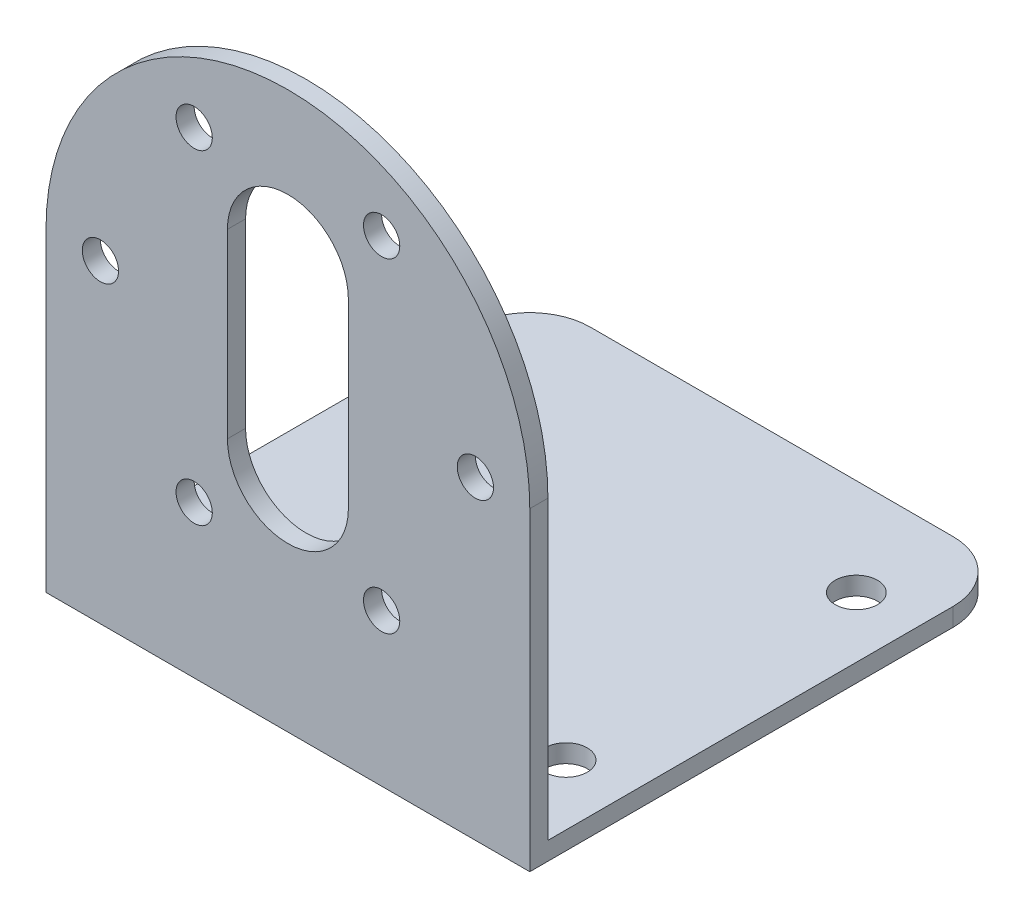
from build123d import *

# Parameters (mm, degrees)
SKETCH_1_R          = 1.5
EXTRUDE_1_DEPTH     = 1.5
SKETCH_2_W          = 40
SKETCH_2_H          = 1.5
EXTRUDE_2_DEPTH     = 38.5
SKETCH_3_R          = 1.75
CUT_EXTRUDE_1_DEPTH = 47
FILLET_1_R          = 5


with BuildPart() as part:
    # 草图1 → 凸台-拉伸1 (new body)
    with BuildSketch(Plane.XY):
        with BuildLine():
            Line((-20, 0), (-20, -26))
            Line((-20, -26), (20, -26))
            Line((20, -26), (20, 0))
            ThreePointArc((20, 0), (0, 20), (-20, 0))
        make_face()
        with Locations((7.75, 13.423393759)):
            Circle(SKETCH_1_R, mode=Mode.SUBTRACT)
        with Locations((-7.75, 13.423393759)):
            Circle(SKETCH_1_R, mode=Mode.SUBTRACT)
        with Locations((-15.5, 0)):
            Circle(SKETCH_1_R, mode=Mode.SUBTRACT)
        with Locations((-7.75, -13.423393759)):
            Circle(SKETCH_1_R, mode=Mode.SUBTRACT)
        with Locations((7.75, -13.423393759)):
            Circle(SKETCH_1_R, mode=Mode.SUBTRACT)
        with Locations((15.5, 0)):
            Circle(SKETCH_1_R, mode=Mode.SUBTRACT)
        with BuildLine():
            Line((5, -7.5), (5, 7.5))
            ThreePointArc((5, 7.5), (0, 12.5), (-5, 7.5))
            Line((-5, 7.5), (-5, -7.5))
            ThreePointArc((-5, -7.5), (0, -12.5), (5, -7.5))
        make_face(mode=Mode.SUBTRACT)
    extrude(amount=EXTRUDE_1_DEPTH)

    # 草图2 → 凸台-拉伸2 (add)
    with BuildSketch(Plane(origin=(0, 0, 0), x_dir=(-1, 0, 0), z_dir=(0, 0, -1))):
        with Locations((0, -25.25)):
            Rectangle(SKETCH_2_W, SKETCH_2_H)
    extrude(amount=EXTRUDE_2_DEPTH)

    # 草图3 → 切除-拉伸1 (cut, through all)
    with BuildSketch(Plane.XZ.offset(26)):
        with Locations((-15, -6.5)):
            Circle(SKETCH_3_R)
        with Locations((15, -6.5)):
            Circle(SKETCH_3_R)
        with Locations((-15, -30.5)):
            Circle(SKETCH_3_R)
        with Locations((15, -30.5)):
            Circle(SKETCH_3_R)
    extrude(amount=-CUT_EXTRUDE_1_DEPTH, mode=Mode.SUBTRACT)

    # 圆角1
    fillet_1_edges = [part.edges().sort_by_distance(p)[0] for p in [
        (20, -25.25, -38.5),
        (-20, -25.25, -38.5),
    ]]
    fillet(fillet_1_edges, radius=FILLET_1_R)


solid = part.part
